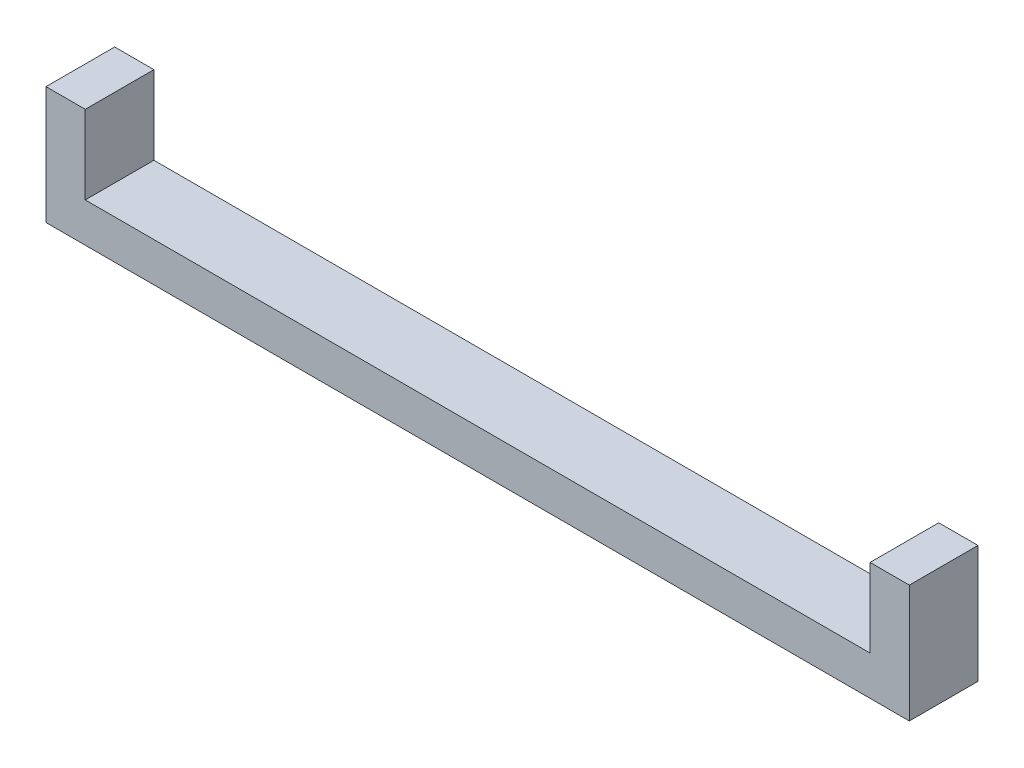
from build123d import *

# Parameters (mm, degrees)
EXTRUDE_THIN1_DEPTH = 17.5005


with BuildPart() as part:
    # Sketch1 → Extrude-Thin1 (new body, symmetric)
    with BuildSketch(Plane.XY):
        Polygon((0, 0), (200, 0), (200, 40), (220, 40), (220, -20), (0, -20), align=None)
    extrude_thin1 = extrude(amount=EXTRUDE_THIN1_DEPTH, both=True)

    # Mirror1: Extrude-Thin1 across plane
    add(extrude_thin1.mirror(Plane(origin=(0, 0, 0), x_dir=(0, 0, 1), z_dir=(1, 0, 0))))


solid = part.part
